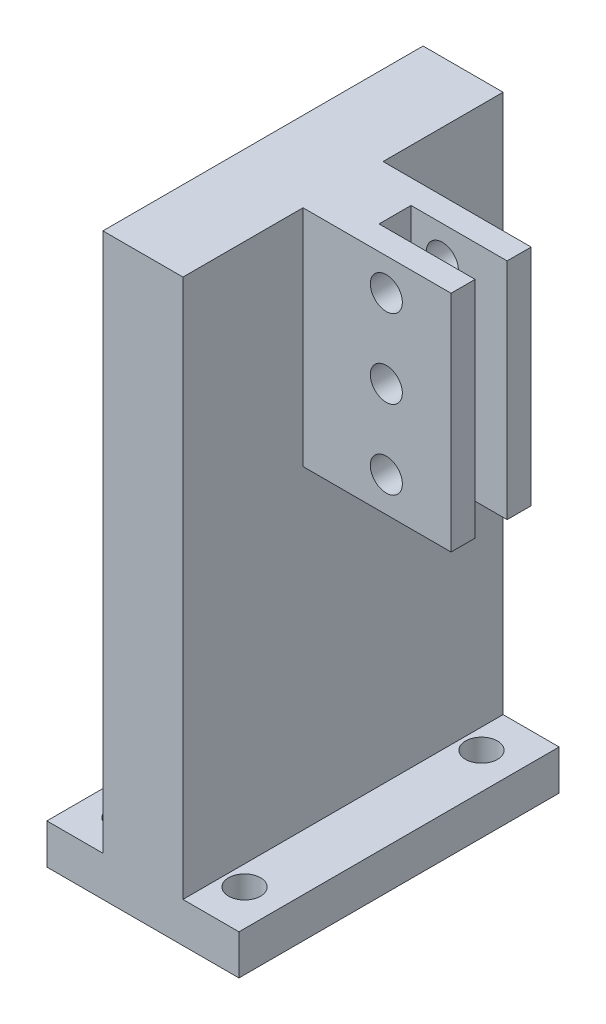
from build123d import *

# Parameters (mm, degrees)
SKETCH_1_W          = 24
SKETCH_1_H          = 40
SKETCH_1_R          = 2
EXTRUDE_1_DEPTH     = 5
EXTRUDE_5_DEPTH     = 67.34
SKETCH_10_W         = 10
SKETCH_10_H         = 28
EXTRUDE_6_DEPTH     = 18.5
SKETCH_12_R         = 2
CUT_EXTRUDE_4_DEPTH = 24.5
SKETCH_13_W         = 12
SKETCH_13_H         = 28
CUT_EXTRUDE_5_DEPTH = 2


with BuildPart() as part:
    # 草图1 → 凸台-拉伸1 (new body)
    with BuildSketch(Plane(origin=(0, 0, 0), x_dir=(1, 0, 0), z_dir=(0, 1, 0))):
        Rectangle(SKETCH_1_W, SKETCH_1_H)
        with Locations((7.5, -14.8)):
            Circle(SKETCH_1_R, mode=Mode.SUBTRACT)
        with Locations((-7.5, -14.8)):
            Circle(SKETCH_1_R, mode=Mode.SUBTRACT)
        with Locations((-7.5, 14.8)):
            Circle(SKETCH_1_R, mode=Mode.SUBTRACT)
        with Locations((7.5, 14.8)):
            Circle(SKETCH_1_R, mode=Mode.SUBTRACT)
    extrude(amount=EXTRUDE_1_DEPTH)

    # 草图8 → 凸台-拉伸5 (add)
    with BuildSketch(Plane(origin=(0, 5, 0), x_dir=(1, 0, 0), z_dir=(0, 1, 0))):
        Polygon((-5, 0), (-5, -20), (5, -20), (5, 20), (-5, 20), align=None)
    extrude(amount=EXTRUDE_5_DEPTH)

    # 草图10 → 凸台-拉伸6 (add)
    with BuildSketch(Plane(origin=(5, 0, 0), x_dir=(0, 0, -1), z_dir=(1, 0, 0))):
        with Locations((0, 58.34)):
            Rectangle(SKETCH_10_W, SKETCH_10_H)
    extrude(amount=EXTRUDE_6_DEPTH)

    # 草图12 → 切除-拉伸4 (cut)
    with BuildSketch(Plane(origin=(0, 0, -5), x_dir=(-1, 0, 0), z_dir=(0, 0, -1))):
        with Locations((-15.41, 68.31)):
            Circle(SKETCH_12_R)
        with Locations((-15.41, 58.49)):
            Circle(SKETCH_12_R)
        with Locations((-15.41, 48.67)):
            Circle(SKETCH_12_R)
    extrude(amount=-CUT_EXTRUDE_4_DEPTH, mode=Mode.SUBTRACT)

    # 草图13 → 切除-拉伸5 (cut, symmetric)
    with BuildSketch(Plane.XY):
        with Locations((17.5, 58.34)):
            Rectangle(SKETCH_13_W, SKETCH_13_H)
    extrude(amount=CUT_EXTRUDE_5_DEPTH, both=True, mode=Mode.SUBTRACT)


solid = part.part
